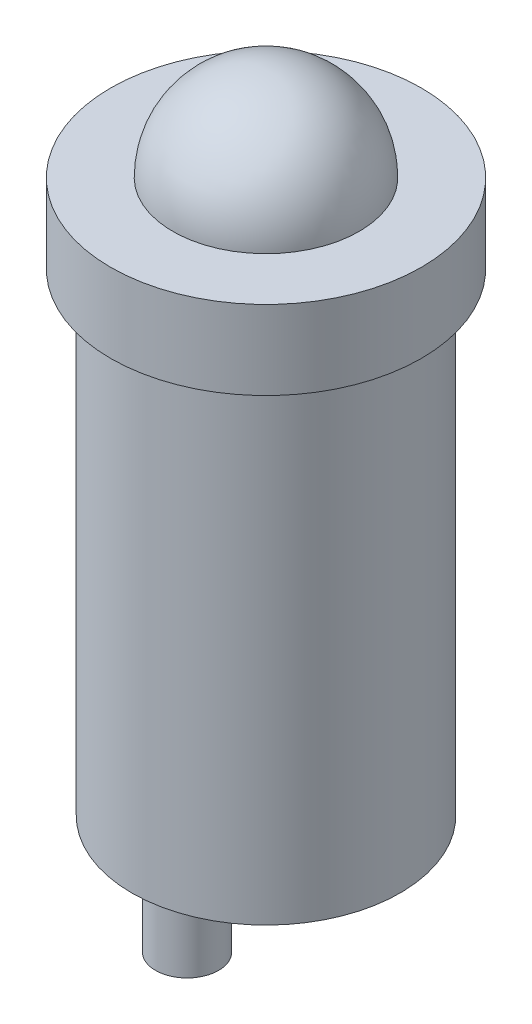
from build123d import *

# Parameters (mm, degrees)
SKETCH1_R             = 2.16
BOSS_EXTRUDE1_DEPTH   = 7.62
SKETCH2_R             = 2.5
BOSS_EXTRUDE2_DEPTH   = 1.27
REVOLVE1_ANGLE        = 180
SKETCH4_R             = 0.508
BOSS_EXTRUDE3_DEPTH   = 1.27
BOSS_EXTRUDE3_2_DEPTH = 1.27


with BuildPart() as part:
    # Sketch1 → Boss-Extrude1 (new body)
    with BuildSketch(Plane(origin=(0, 0, 0), x_dir=(1, 0, 0), z_dir=(0, 1, 0))):
        Circle(SKETCH1_R)
    extrude(amount=BOSS_EXTRUDE1_DEPTH)

    # Sketch2 → Boss-Extrude2 (add)
    with BuildSketch(Plane(origin=(0, 7.62, 0), x_dir=(1, 0, 0), z_dir=(0, 1, 0))):
        Circle(SKETCH2_R)
    extrude(amount=BOSS_EXTRUDE2_DEPTH)


with BuildPart() as body_2:
    # Sketch3 → Revolve1 (revolve)
    with BuildSketch(Plane(origin=(0, 8.89, 0), x_dir=(1, 0, 0), z_dir=(0, 1, 0))):
        with BuildLine():
            Line((1.5, 0), (-1.5, 0))
            ThreePointArc((-1.5, 0), (0, 1.5), (1.5, 0))
        make_face()
    revolve(axis=Axis((1.5, 8.89, 0), (1, 0, 0)), revolution_arc=REVOLVE1_ANGLE)


with BuildPart() as body_3:
    # Sketch4 → Boss-Extrude3 (new body)
    with BuildSketch(Plane.XZ):
        with Locations((0, 1.27)):
            Circle(SKETCH4_R)
    extrude(amount=BOSS_EXTRUDE3_DEPTH)


with BuildPart() as body_4:
    # Sketch4 → Boss-Extrude3 2 (new body)
    with BuildSketch(Plane.XZ):
        with Locations((0, -1.27)):
            Circle(SKETCH4_R)
    extrude(amount=BOSS_EXTRUDE3_2_DEPTH)


solid = Compound([part.part, body_2.part, body_3.part, body_4.part])
